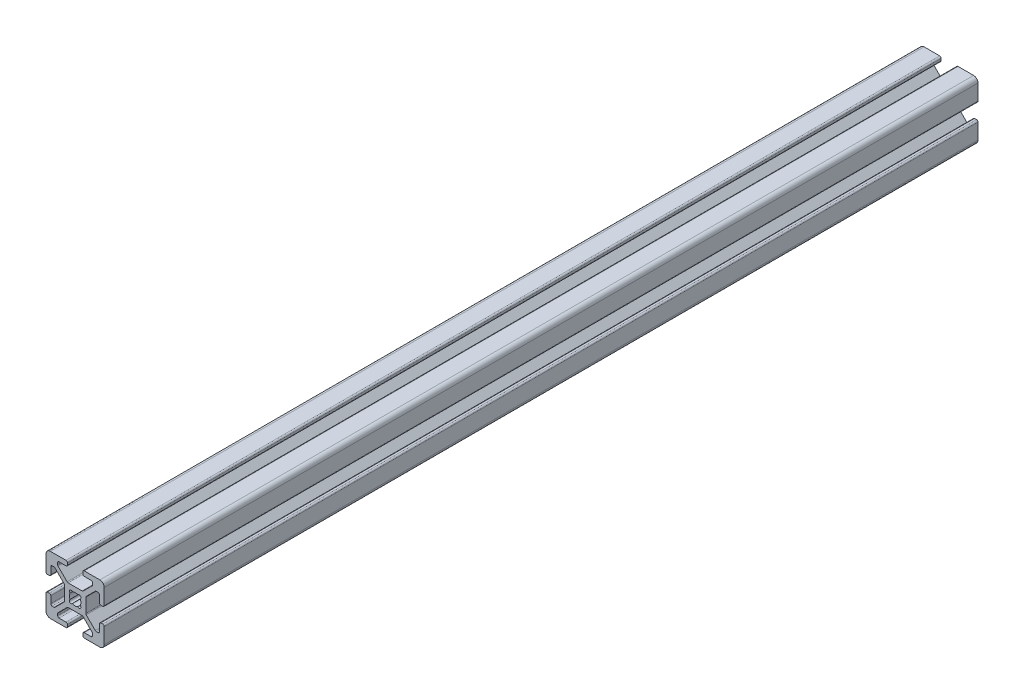
from build123d import *

# Parameters (mm, degrees)
BOSS_EXTRUDE1_DEPTH = 300


with BuildPart() as part:
    # Sketch1 → Boss-Extrude1 (new body)
    with BuildSketch(Plane.XY):
        with BuildLine():
            Line((-2.746356642, -3.807016814), (-5.847983186, -6.908643358))
            ThreePointArc((-5.847983186, -6.908643358), (-5.956791575, -7.07148662), (-5.995, -7.263573344))
            Line((-5.995, -7.263573344), (-5.995, -7.858053199))
            ThreePointArc((-5.995, -7.858053199), (-5.847983186, -8.212983186), (-5.493053199, -8.36))
            Line((-5.493053199, -8.36), (-3.131946801, -8.36))
            ThreePointArc((-3.131946801, -8.36), (-2.777016814, -8.507016814), (-2.63, -8.861946801))
            Line((-2.63, -8.861946801), (-2.63, -9.498053199))
            ThreePointArc((-2.63, -9.498053199), (-2.777016814, -9.852983186), (-3.131946801, -10))
            Line((-3.131946801, -10), (-8.5, -10))
            ThreePointArc((-8.5, -10), (-9.560660172, -9.560660172), (-10, -8.5))
            Line((-10, -8.5), (-10, -3.131946801))
            ThreePointArc((-10, -3.131946801), (-9.852983186, -2.777016814), (-9.498053199, -2.63))
            Line((-9.498053199, -2.63), (-8.861946801, -2.63))
            ThreePointArc((-8.861946801, -2.63), (-8.507016814, -2.777016814), (-8.36, -3.131946801))
            Line((-8.36, -3.131946801), (-8.36, -5.493053199))
            ThreePointArc((-8.36, -5.493053199), (-8.212983186, -5.847983186), (-7.858053199, -5.995))
            Line((-7.858053199, -5.995), (-7.263573344, -5.995))
            ThreePointArc((-7.263573344, -5.995), (-7.07148662, -5.956791575), (-6.908643358, -5.847983186))
            Line((-6.908643358, -5.847983186), (-3.807016814, -2.746356642))
            ThreePointArc((-3.807016814, -2.746356642), (-3.698208425, -2.58351338), (-3.66, -2.391426656))
            Line((-3.66, -2.391426656), (-3.66, 2.391426656))
            ThreePointArc((-3.66, 2.391426656), (-3.698208425, 2.58351338), (-3.807016814, 2.746356642))
            Line((-3.807016814, 2.746356642), (-6.908643358, 5.847983186))
            ThreePointArc((-6.908643358, 5.847983186), (-7.07148662, 5.956791575), (-7.263573344, 5.995))
            Line((-7.263573344, 5.995), (-7.858053199, 5.995))
            ThreePointArc((-7.858053199, 5.995), (-8.212983186, 5.847983186), (-8.36, 5.493053199))
            Line((-8.36, 5.493053199), (-8.36, 3.131946801))
            ThreePointArc((-8.36, 3.131946801), (-8.507016814, 2.777016814), (-8.861946801, 2.63))
            Line((-8.861946801, 2.63), (-9.498053199, 2.63))
            ThreePointArc((-9.498053199, 2.63), (-9.852983186, 2.777016814), (-10, 3.131946801))
            Line((-10, 3.131946801), (-10, 8.5))
            ThreePointArc((-10, 8.5), (-9.560660172, 9.560660172), (-8.5, 10))
            Line((-8.5, 10), (-3.131946801, 10))
            ThreePointArc((-3.131946801, 10), (-2.777016814, 9.852983186), (-2.63, 9.498053199))
            Line((-2.63, 9.498053199), (-2.63, 8.861946801))
            ThreePointArc((-2.63, 8.861946801), (-2.777016814, 8.507016814), (-3.131946801, 8.36))
            Line((-3.131946801, 8.36), (-5.493053199, 8.36))
            ThreePointArc((-5.493053199, 8.36), (-5.847983186, 8.212983186), (-5.995, 7.858053199))
            Line((-5.995, 7.858053199), (-5.995, 7.263573344))
            ThreePointArc((-5.995, 7.263573344), (-5.956791575, 7.07148662), (-5.847983186, 6.908643358))
            Line((-5.847983186, 6.908643358), (-2.746356642, 3.807016814))
            ThreePointArc((-2.746356642, 3.807016814), (-2.58351338, 3.698208425), (-2.391426656, 3.66))
            Line((-2.391426656, 3.66), (2.391426656, 3.66))
            ThreePointArc((2.391426656, 3.66), (2.58351338, 3.698208425), (2.746356642, 3.807016814))
            Line((2.746356642, 3.807016814), (5.847983186, 6.908643358))
            ThreePointArc((5.847983186, 6.908643358), (5.956791575, 7.07148662), (5.995, 7.263573344))
            Line((5.995, 7.263573344), (5.995, 7.858053199))
            ThreePointArc((5.995, 7.858053199), (5.847983186, 8.212983186), (5.493053199, 8.36))
            Line((5.493053199, 8.36), (3.131946801, 8.36))
            ThreePointArc((3.131946801, 8.36), (2.777016814, 8.507016814), (2.63, 8.861946801))
            Line((2.63, 8.861946801), (2.63, 9.498053199))
            ThreePointArc((2.63, 9.498053199), (2.777016814, 9.852983186), (3.131946801, 10))
            Line((3.131946801, 10), (8.5, 10))
            ThreePointArc((8.5, 10), (9.560660172, 9.560660172), (10, 8.5))
            Line((10, 8.5), (10, 3.131946801))
            ThreePointArc((10, 3.131946801), (9.852983186, 2.777016814), (9.498053199, 2.63))
            Line((9.498053199, 2.63), (8.861946801, 2.63))
            ThreePointArc((8.861946801, 2.63), (8.507016814, 2.777016814), (8.36, 3.131946801))
            Line((8.36, 3.131946801), (8.36, 5.493053199))
            ThreePointArc((8.36, 5.493053199), (8.212983186, 5.847983186), (7.858053199, 5.995))
            Line((7.858053199, 5.995), (7.263573344, 5.995))
            ThreePointArc((7.263573344, 5.995), (7.07148662, 5.956791575), (6.908643358, 5.847983186))
            Line((6.908643358, 5.847983186), (3.807016814, 2.746356642))
            ThreePointArc((3.807016814, 2.746356642), (3.698208425, 2.58351338), (3.66, 2.391426656))
            Line((3.66, 2.391426656), (3.66, -2.391426656))
            ThreePointArc((3.66, -2.391426656), (3.698208425, -2.58351338), (3.807016814, -2.746356642))
            Line((3.807016814, -2.746356642), (6.908643358, -5.847983186))
            ThreePointArc((6.908643358, -5.847983186), (7.07148662, -5.956791575), (7.263573344, -5.995))
            Line((7.263573344, -5.995), (7.858053199, -5.995))
            ThreePointArc((7.858053199, -5.995), (8.212983186, -5.847983186), (8.36, -5.493053199))
            Line((8.36, -5.493053199), (8.36, -3.131946801))
            ThreePointArc((8.36, -3.131946801), (8.507016814, -2.777016814), (8.861946801, -2.63))
            Line((8.861946801, -2.63), (9.498053199, -2.63))
            ThreePointArc((9.498053199, -2.63), (9.852983186, -2.777016814), (10, -3.131946801))
            Line((10, -3.131946801), (10, -8.5))
            ThreePointArc((10, -8.5), (9.560660172, -9.560660172), (8.5, -10))
            Line((8.5, -10), (3.131946801, -10))
            ThreePointArc((3.131946801, -10), (2.777016814, -9.852983186), (2.63, -9.498053199))
            Line((2.63, -9.498053199), (2.63, -8.861946801))
            ThreePointArc((2.63, -8.861946801), (2.777016814, -8.507016814), (3.131946801, -8.36))
            Line((3.131946801, -8.36), (5.493053199, -8.36))
            ThreePointArc((5.493053199, -8.36), (5.847983186, -8.212983186), (5.995, -7.858053199))
            Line((5.995, -7.858053199), (5.995, -7.263573344))
            ThreePointArc((5.995, -7.263573344), (5.956791575, -7.07148662), (5.847983186, -6.908643358))
            Line((5.847983186, -6.908643358), (2.746356642, -3.807016814))
            ThreePointArc((2.746356642, -3.807016814), (2.58351338, -3.698208425), (2.391426656, -3.66))
            Line((2.391426656, -3.66), (-2.391426656, -3.66))
            ThreePointArc((-2.391426656, -3.66), (-2.58351338, -3.698208425), (-2.746356642, -3.807016814))
        make_face()
        with BuildLine():
            ThreePointArc((-1.767678053, 0.935582333), (-2, 0), (-1.767678053, -0.935582333))
            ThreePointArc((-1.767678053, -0.935582333), (-1.834942097, -1.834942097), (-0.935582333, -1.767678053))
            ThreePointArc((-0.935582333, -1.767678053), (0, -2), (0.935582333, -1.767678053))
            ThreePointArc((0.935582333, -1.767678053), (1.834942097, -1.834942097), (1.767678053, -0.935582333))
            ThreePointArc((1.767678053, -0.935582333), (2, 0), (1.767678053, 0.935582333))
            ThreePointArc((1.767678053, 0.935582333), (1.834942097, 1.834942097), (0.935582333, 1.767678053))
            ThreePointArc((0.935582333, 1.767678053), (0, 2), (-0.935582333, 1.767678053))
            ThreePointArc((-0.935582333, 1.767678053), (-1.834942097, 1.834942097), (-1.767678053, 0.935582333))
        make_face(mode=Mode.SUBTRACT)
    extrude(amount=BOSS_EXTRUDE1_DEPTH)


solid = part.part
